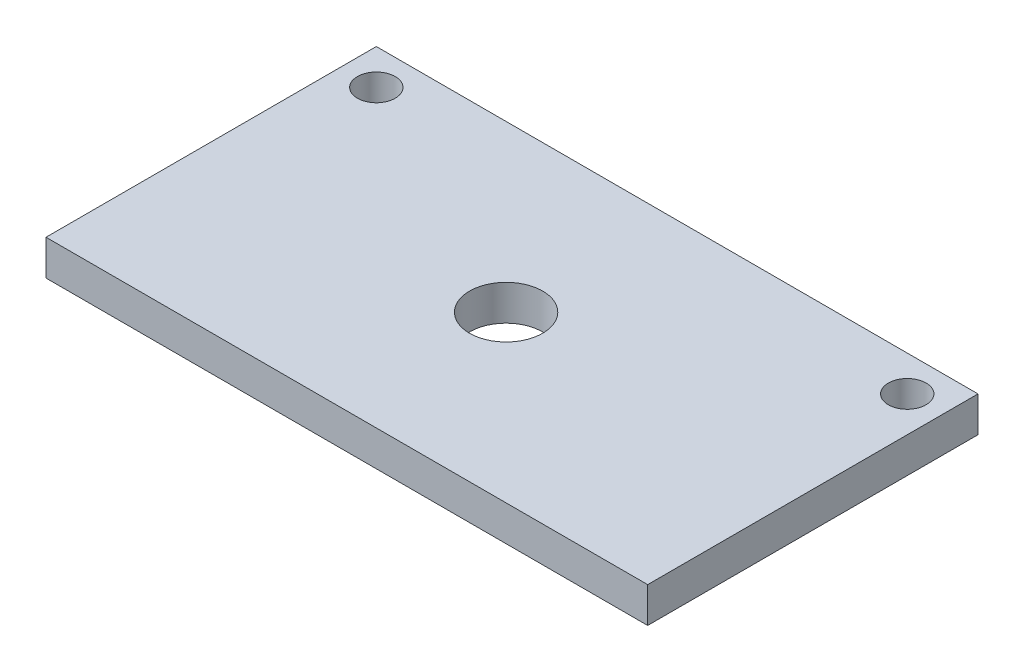
from build123d import *

# Parameters (mm, degrees)
SKETCH1_W           = 51
SKETCH1_H           = 28
BOSS_EXTRUDE1_DEPTH = 3
SKETCH2_R           = 1.6
CUT_EXTRUDE1_DEPTH  = 3
SKETCH3_R           = 3.1
CUT_EXTRUDE2_DEPTH  = 3


with BuildPart() as part:
    # Sketch1 → Boss-Extrude1 (new body)
    with BuildSketch(Plane(origin=(0, 0, 0), x_dir=(1, 0, 0), z_dir=(0, 1, 0))):
        with Locations((-1.082278481, 0.240506329)):
            Rectangle(SKETCH1_W, SKETCH1_H)
    extrude(amount=BOSS_EXTRUDE1_DEPTH)

    # Sketch2 → Cut-Extrude1 (cut)
    with BuildSketch(Plane(origin=(0, 3, 0), x_dir=(1, 0, 0), z_dir=(0, 1, 0))):
        with Locations((-23.582278481, 11.240506329)):
            Circle(SKETCH2_R)
        with Locations((21.417721519, 11.240506329)):
            Circle(SKETCH2_R)
    extrude(amount=-CUT_EXTRUDE1_DEPTH, mode=Mode.SUBTRACT)

    # Sketch3 → Cut-Extrude2 (cut)
    with BuildSketch(Plane(origin=(0, 3, 0), x_dir=(1, 0, 0), z_dir=(0, 1, 0))):
        with Locations((-1.582278481, 0.240506329)):
            Circle(SKETCH3_R)
    extrude(amount=-CUT_EXTRUDE2_DEPTH, mode=Mode.SUBTRACT)


solid = part.part
